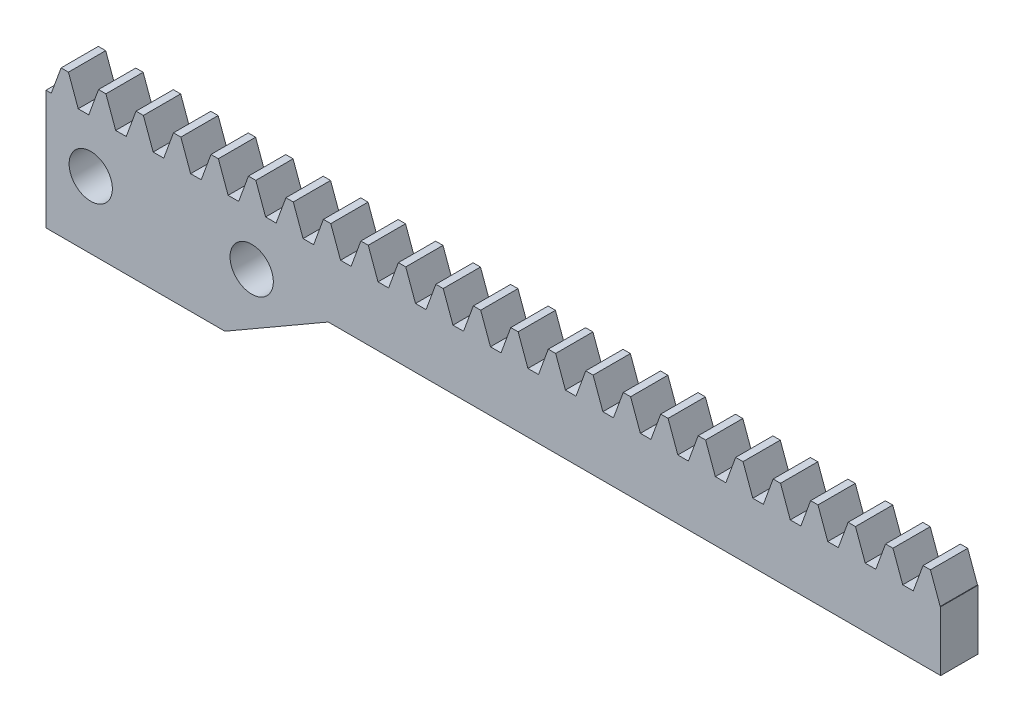
from build123d import *

# Parameters (mm, degrees)
BLANKSKE_W               = 60
BLANKSKE_H               = 5.8
BLANK_DEPTH              = 2.5
TOOTHCUTSIM_DEPTH        = 61.331500893
TEETHCUTS_COUNT          = 25
TEETHCUTS_PITCH          = 2.51327412
EXTRUDE_1_DEPTH          = 2.5
SKETCH_3_R               = 1.45
CUT_EXTRUDE_1_DEPTH      = 23
CUT_EXTRUDE_1_DEPTH_BACK = 12


with BuildPart() as part:
    # BlankSke → Blank (new body)
    with BuildSketch(Plane.XY):
        with Locations((30, 2.9)):
            Rectangle(BLANKSKE_W, BLANKSKE_H)
    extrude(amount=-BLANK_DEPTH)

    # TooCutSkeSim → ToothCutSim (cut, through all)
    with BuildSketch(Plane.XY):
        Polygon((0.354348296, 4), (-0.354348296, 4), (-1.018739561, 5.8254), (1.018739561, 5.8254), align=None)
    toothcutsim = extrude(amount=-TOOTHCUTSIM_DEPTH, mode=Mode.SUBTRACT)

    # TeethCuts: ToothCutSim ×25
    with Locations(*[(i * TEETHCUTS_PITCH, 0, 0) for i in range(1, TEETHCUTS_COUNT)]):
        add(toothcutsim, mode=Mode.SUBTRACT)

    # 草图2 → 凸台-拉伸1 (add)
    with BuildSketch(Plane(origin=(0, 0, -2.5), x_dir=(-1, 0, 0), z_dir=(0, 0, -1))):
        Polygon((0, 4), (0, -4), (-12, -4), (-18.92820323, 0), align=None)
    extrude(amount=-EXTRUDE_1_DEPTH)

    # 草图3 → 切除-拉伸1 (cut, two sides)
    with BuildSketch(Plane(origin=(0, 0, -2.5), x_dir=(-1, 0, 0), z_dir=(0, 0, -1))) as cut_extrude_1_sk:
        with Locations((-3, 0.5)):
            Circle(SKETCH_3_R)
        with Locations((-13.794228634, 0.5)):
            Circle(SKETCH_3_R)
    extrude(amount=CUT_EXTRUDE_1_DEPTH, mode=Mode.SUBTRACT)
    extrude(cut_extrude_1_sk.sketch, amount=-CUT_EXTRUDE_1_DEPTH_BACK, mode=Mode.SUBTRACT)


solid = part.part
